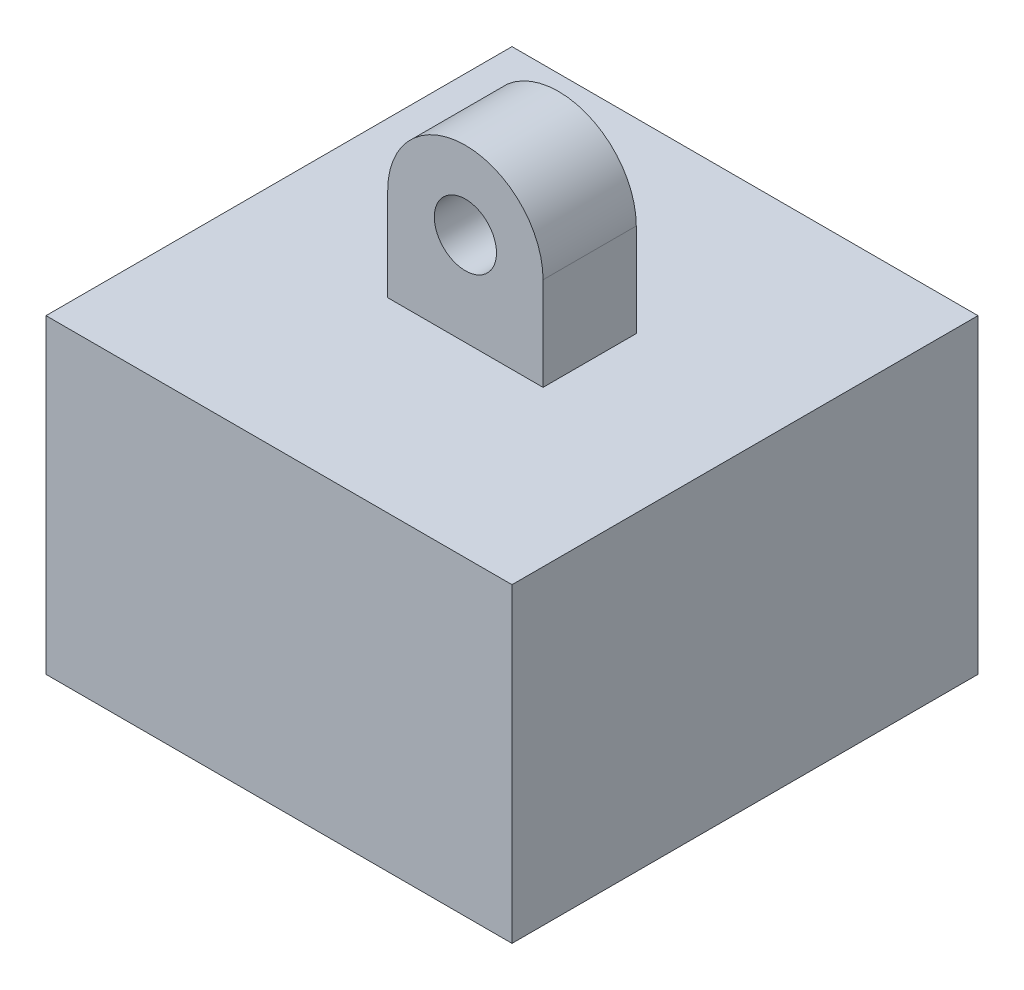
from build123d import *

# Parameters (mm, degrees)
SKETCH1_W           = 15
SKETCH1_H           = 15
BOSS_EXTRUDE1_DEPTH = 10
SKETCH4_R           = 1
BOSS_EXTRUDE2_DEPTH = 1.5


with BuildPart() as part:
    # Sketch1 → Boss-Extrude1 (new body)
    with BuildSketch(Plane.XZ):
        with Locations((7.5, -7.5)):
            Rectangle(SKETCH1_W, SKETCH1_H)
    extrude(amount=BOSS_EXTRUDE1_DEPTH)

    # Sketch4 → Boss-Extrude2 (add, symmetric)
    with BuildSketch(Plane.XY.offset(-7.5)):
        with BuildLine():
            ThreePointArc((10, 3), (7.5, 5.5), (5, 3))
            Line((5, 3), (5, 0))
            Line((5, 0), (10, 0))
            Line((10, 0), (10, 3))
        make_face()
        with Locations((7.5, 3)):
            Circle(SKETCH4_R, mode=Mode.SUBTRACT)
    extrude(amount=BOSS_EXTRUDE2_DEPTH, both=True)


solid = part.part
